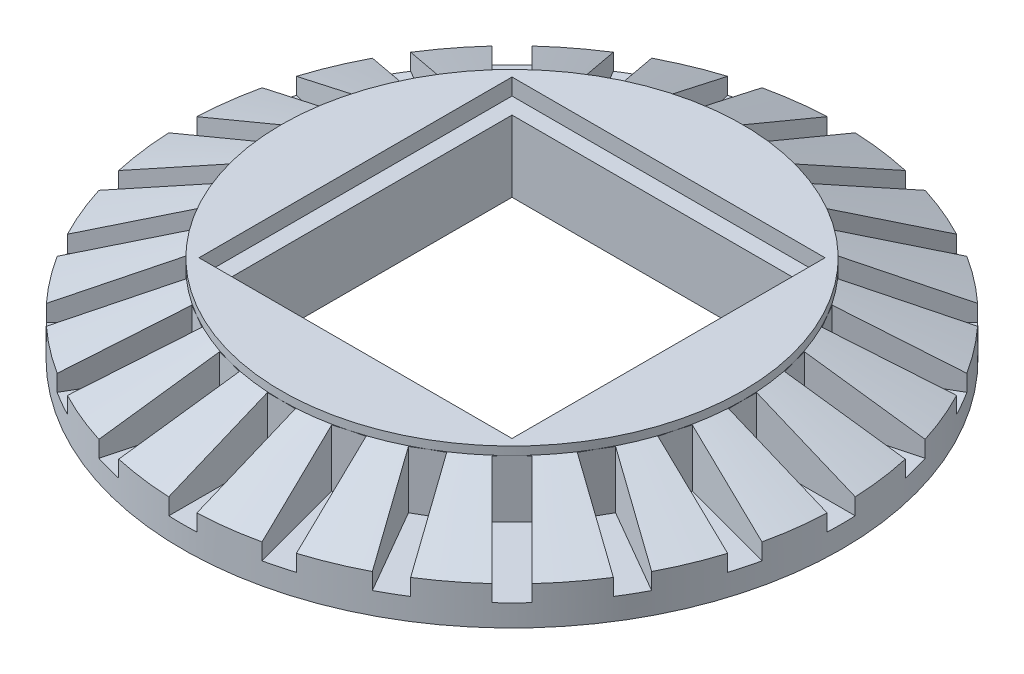
from build123d import *

# Parameters (mm, degrees)
CUT_EXTRUDE1_DEPTH  = 1.349999904
CIRPATTERN1_COUNT   = 24
SKETCH17_R          = 31.75
BOSS_EXTRUDE1_DEPTH = 2.1
SKETCH15_W          = 26.9875
SKETCH15_H          = 26.9875
CUT_EXTRUDE2_DEPTH  = 9.45
SKETCH16_W          = 30.1625
SKETCH16_H          = 30.1625
CUT_EXTRUDE3_DEPTH  = 1.5875


with BuildPart() as part:
    # Sketch2 → Revolve1 (revolve)
    with BuildSketch(Plane.XY):
        Polygon((0, 0), (31.75, 0), (31.75, 1.5875), (22.225, 5.55625), (22.225, 6.35), (0, 6.35), align=None)
    revolve(axis=Axis((0, 6.35, 0), (0, -1, 0)))

    # Sketch3 → Cut-Extrude1 (cut, symmetric)
    with BuildSketch(Plane.XY):
        Polygon((22.225, 6.35), (31.75, 2.38125), (31.75, 0), (22.225, 0), align=None)
    cut_extrude1 = extrude(amount=CUT_EXTRUDE1_DEPTH, both=True, mode=Mode.SUBTRACT)

    # CirPattern1: Cut-Extrude1 ×24 about axis
    cirpattern1_axis = Axis((0, 0, 0), (0, 1, 0))
    for i in range(1, CIRPATTERN1_COUNT):
        add(cut_extrude1.rotate(cirpattern1_axis, i * 360 / CIRPATTERN1_COUNT), mode=Mode.SUBTRACT)

    # Sketch17 → Boss-Extrude1 (add)
    with BuildSketch(Plane.XZ):
        Circle(SKETCH17_R)
    extrude(amount=BOSS_EXTRUDE1_DEPTH)

    # Sketch15 → Cut-Extrude2 (cut, through all)
    with BuildSketch(Plane(origin=(0, 6.35, 0), x_dir=(1, 0, 0), z_dir=(0, 1, 0))):
        Rectangle(SKETCH15_W, SKETCH15_H)
    extrude(amount=-CUT_EXTRUDE2_DEPTH, mode=Mode.SUBTRACT)

    # Sketch16 → Cut-Extrude3 (cut)
    with BuildSketch(Plane(origin=(0, 6.35, 0), x_dir=(1, 0, 0), z_dir=(0, 1, 0))):
        Rectangle(SKETCH16_W, SKETCH16_H)
    extrude(amount=-CUT_EXTRUDE3_DEPTH, mode=Mode.SUBTRACT)


solid = part.part
